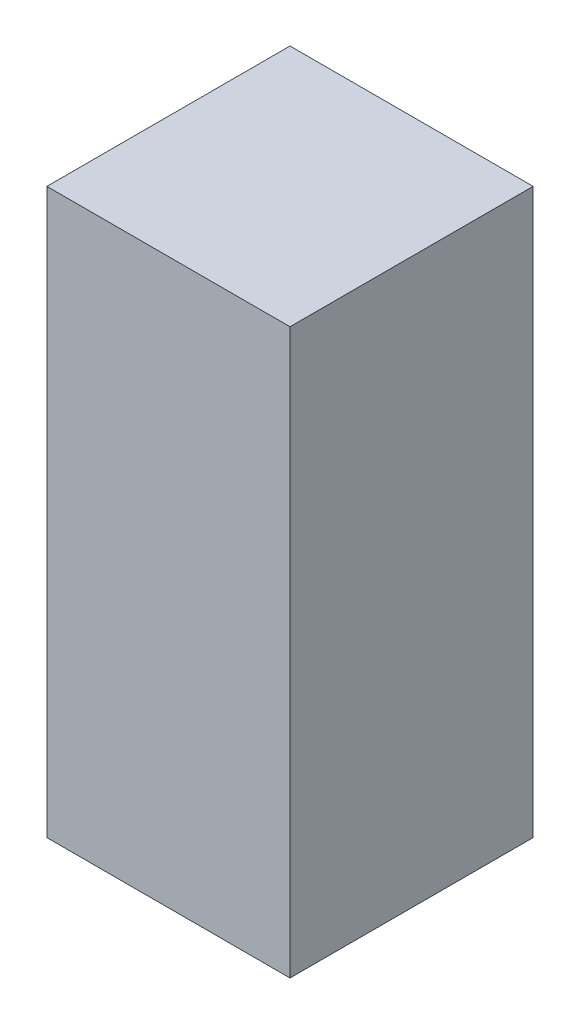
from build123d import *

# Parameters (mm, degrees)
SKETCH1_W           = 25.4
SKETCH1_H           = 25.4
BOSS_EXTRUDE1_DEPTH = 58.928


with BuildPart() as part:
    # Sketch1 → Boss-Extrude1 (new body)
    with BuildSketch(Plane(origin=(0, 0, 0), x_dir=(1, 0, 0), z_dir=(0, 1, 0))):
        Rectangle(SKETCH1_W, SKETCH1_H)
    extrude(amount=BOSS_EXTRUDE1_DEPTH)


solid = part.part
